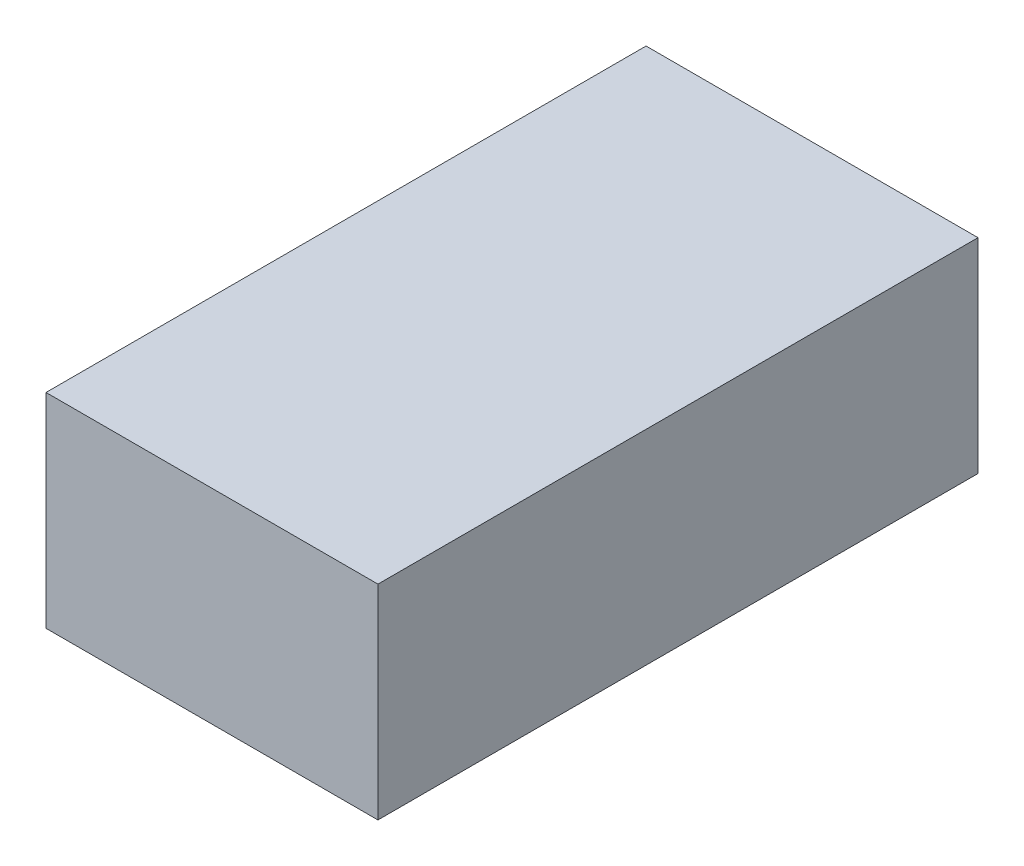
from build123d import *

# Parameters (mm, degrees)
ESQUISSE1_W        = 26
ESQUISSE1_H        = 16
BOSS_EXTRU_1_DEPTH = 47


with BuildPart() as part:
    # Esquisse1 → Boss.-Extru.1 (new body)
    with BuildSketch(Plane.XY):
        with Locations((13, 8)):
            Rectangle(ESQUISSE1_W, ESQUISSE1_H)
    extrude(amount=BOSS_EXTRU_1_DEPTH)


solid = part.part
